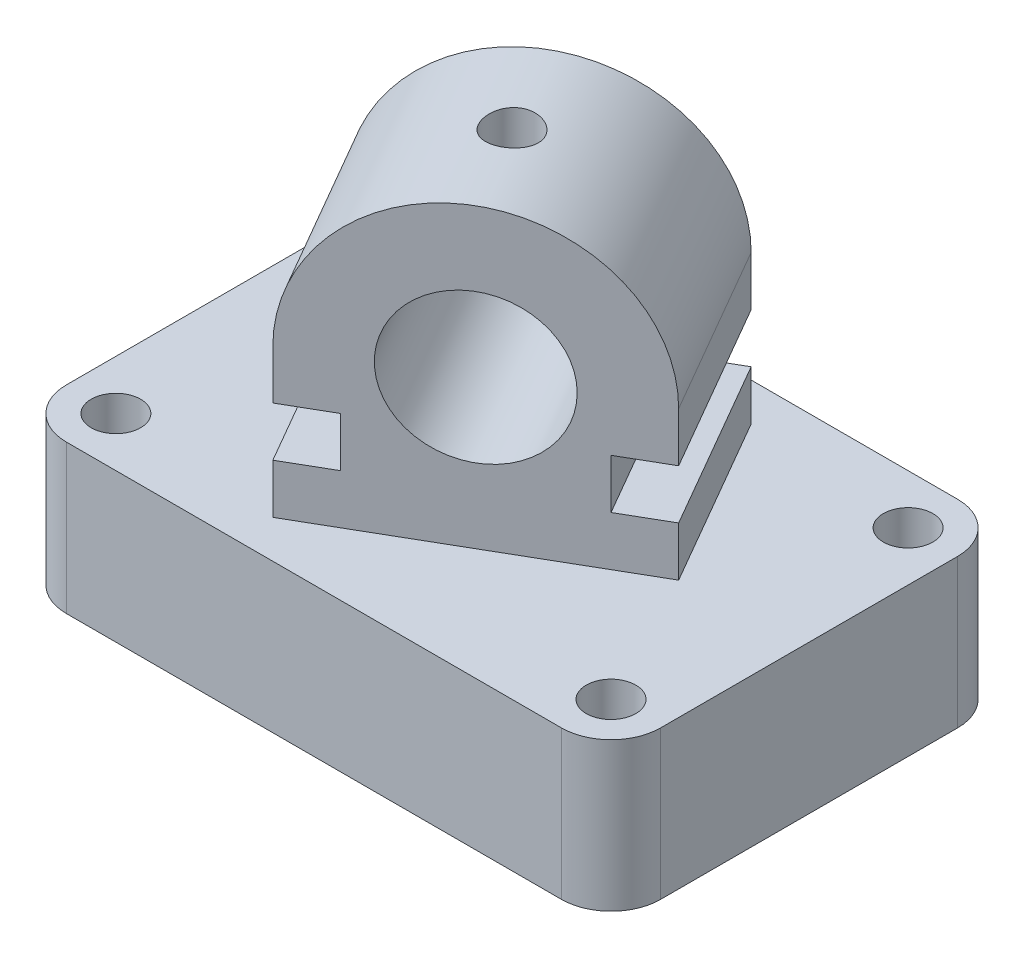
from build123d import *

# Parameters (mm, degrees)
SKETCH1_R           = 3.175
BOSS_EXTRUDE1_DEPTH = 19.05
SKETCH2_R           = 9.525
BOSS_EXTRUDE2_DEPTH = 12.7
CUT_EXTRUDE1_REACH  = 75.232
SKETCH3_R           = 3.175


with BuildPart() as part:
    # Sketch1 → Boss-Extrude1 (new body)
    with BuildSketch(Plane(origin=(0, 0, 0), x_dir=(1, 0, 0), z_dir=(0, 1, 0))):
        with BuildLine():
            Line((-31.75, 25.4), (31.75, 25.4))
            ThreePointArc((31.75, 25.4), (36.240128061, 23.540128061), (38.1, 19.05))
            Line((38.1, 19.05), (38.1, -19.05))
            ThreePointArc((38.1, -19.05), (36.240128061, -23.540128061), (31.75, -25.4))
            Line((31.75, -25.4), (-31.75, -25.4))
            ThreePointArc((-31.75, -25.4), (-36.240128061, -23.540128061), (-38.1, -19.05))
            Line((-38.1, -19.05), (-38.1, 19.05))
            ThreePointArc((-38.1, 19.05), (-36.240128061, 23.540128061), (-31.75, 25.4))
        make_face()
        with Locations((-31.75, 19.05)):
            Circle(SKETCH1_R, mode=Mode.SUBTRACT)
        with Locations((31.75, 19.05)):
            Circle(SKETCH1_R, mode=Mode.SUBTRACT)
        with Locations((31.75, -19.05)):
            Circle(SKETCH1_R, mode=Mode.SUBTRACT)
        with Locations((-31.75, -19.05)):
            Circle(SKETCH1_R, mode=Mode.SUBTRACT)
    extrude(amount=BOSS_EXTRUDE1_DEPTH)

    # Sketch2 → Boss-Extrude2 (add, symmetric)
    with BuildSketch(Plane(origin=(0, 0, 0), x_dir=(0, -1, 0), z_dir=(0.500000000000001, 0, 0.866025403784438))):
        with BuildLine():
            Line((-19.05, 19.05), (-19.05, -19.05))
            Line((-19.05, -19.05), (-25.4, -19.05))
            Line((-25.4, -19.05), (-25.4, -12.7))
            Line((-25.4, -12.7), (-31.75, -12.7))
            Line((-31.75, -12.7), (-31.75, -19.05))
            Line((-31.75, -19.05), (-38.1, -19.05))
            ThreePointArc((-38.1, -19.05), (-57.15, 0), (-38.1, 19.05))
            Line((-38.1, 19.05), (-31.75, 19.05))
            Line((-31.75, 19.05), (-31.75, 12.7))
            Line((-31.75, 12.7), (-25.4, 12.7))
            Line((-25.4, 12.7), (-25.4, 19.05))
            Line((-25.4, 19.05), (-19.05, 19.05))
        make_face()
        with Locations((-38.1, 0)):
            Circle(SKETCH2_R, mode=Mode.SUBTRACT)
    extrude(amount=BOSS_EXTRUDE2_DEPTH, both=True)

    # Sketch3 → Cut-Extrude1 (cut, up to next)
    with BuildSketch(Plane(origin=(0, 57.15, 0), x_dir=(1, 0, 0), z_dir=(0, 1, 0)), mode=Mode.PRIVATE) as cut_extrude1_sk1:
        Circle(SKETCH3_R)
    cut_extrude1_tool1 = extrude(cut_extrude1_sk1.sketch, amount=-CUT_EXTRUDE1_REACH, mode=Mode.PRIVATE) & part.part
    add(cut_extrude1_tool1.solids().sort_by_distance((0, 57.15, 0))[0], mode=Mode.SUBTRACT)


solid = part.part
